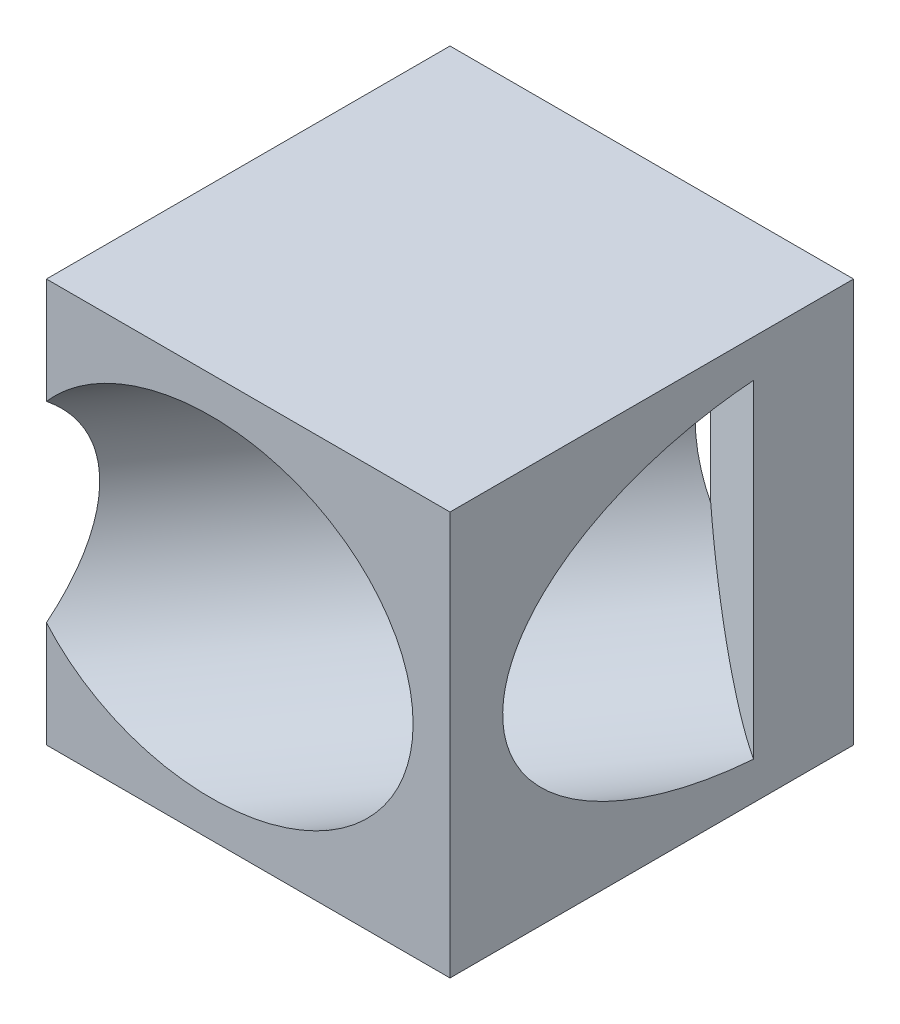
from build123d import *

# Parameters (mm, degrees)
SKETCH1_W           = 140
SKETCH1_H           = 100
BOSS_EXTRUDE1_DEPTH = 100
SKETCH2_R           = 41
CUT_EXTRUDE1_DEPTH  = 163.215905518
SKETCH3_W           = 20
SKETCH3_H           = 100
CUT_EXTRUDE2_DEPTH  = 101
SKETCH4_W           = 10
SKETCH4_H           = 100
CUT_EXTRUDE3_DEPTH  = 101
SKETCH5_R           = 41
BOSS_EXTRUDE2_DEPTH = 20.3
CUT_EXTRUDE4_DEPTH  = 101


with BuildPart() as part:
    # Sketch1 → Boss-Extrude1 (new body)
    with BuildSketch(Plane.XY):
        Rectangle(SKETCH1_W, SKETCH1_H)
    extrude(amount=BOSS_EXTRUDE1_DEPTH)

    # Sketch2 → Cut-Extrude1 (cut, through all)
    with BuildSketch(Plane(origin=(-70.013926023, 0, 99.990248894), x_dir=(0, -1, 0), z_dir=(-0.573576436, 0, 0.819152044))):
        with Locations((0, 58.017000535)):
            Circle(SKETCH2_R)
    extrude(amount=-CUT_EXTRUDE1_DEPTH, mode=Mode.SUBTRACT)

    # Sketch3 → Cut-Extrude2 (cut, through all)
    with BuildSketch(Plane.XY.offset(100)):
        with Locations((-60, 0)):
            Rectangle(SKETCH3_W, SKETCH3_H)
    extrude(amount=-CUT_EXTRUDE2_DEPTH, mode=Mode.SUBTRACT)

    # Sketch4 → Cut-Extrude3 (cut, through all)
    with BuildSketch(Plane.XY.offset(100)):
        with Locations((-45, 0)):
            Rectangle(SKETCH4_W, SKETCH4_H)
        with Locations((65, 0)):
            Rectangle(SKETCH4_W, SKETCH4_H)
    extrude(amount=-CUT_EXTRUDE3_DEPTH, mode=Mode.SUBTRACT)

    # Sketch5 → Boss-Extrude2 (add)
    with BuildSketch(Plane(origin=(19.7393957, 0, -28.190778624), x_dir=(-0.819152044, 0, -0.573576436), z_dir=(0.573576436, 0, -0.819152044))):
        with Locations((-58.017000535, 0)):
            Circle(SKETCH5_R)
    extrude(amount=-BOSS_EXTRUDE2_DEPTH)

    # Sketch6 → Cut-Extrude4 (cut, through all)
    with BuildSketch(Plane(origin=(0, 50, 0), x_dir=(1, 0, 0), z_dir=(0, 1, 0))):
        Polygon((60, 0), (-40, 0), (-40, 38.622200476), (122.468168518, 38.622200476), (119.926290674, -91.2591408), (60, -91.2591408), align=None)
    extrude(amount=-CUT_EXTRUDE4_DEPTH, mode=Mode.SUBTRACT)


solid = part.part
